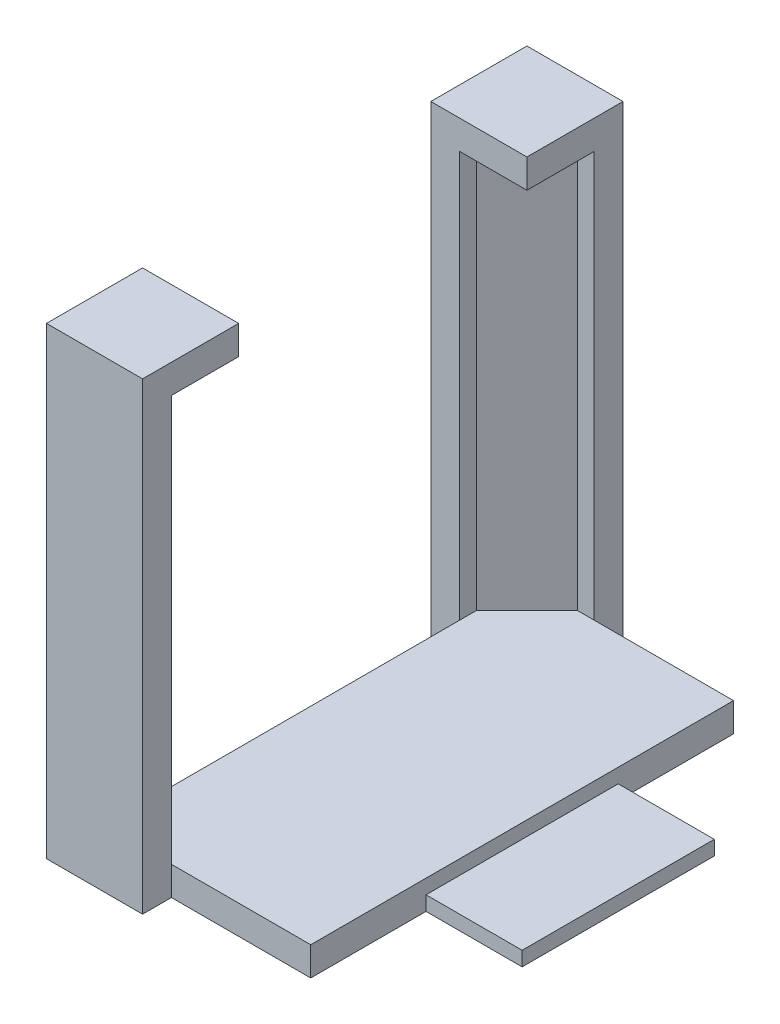
from build123d import *

# Parameters (mm, degrees)
SKETCH1_W           = 21.5
SKETCH1_H           = 44
BOSS_EXTRUDE1_DEPTH = 3
SKETCH1_3_W         = 10
SKETCH1_3_H         = 20
BOSS_EXTRUDE2_DEPTH = 1.5
BOSS_EXTRUDE3_DEPTH = 45.25
SKETCH2_W           = 10
SKETCH2_H           = 10
BOSS_EXTRUDE4_DEPTH = 3
CHAMFER1_SIZE       = 5.25


with BuildPart() as part:
    # Sketch1 → Boss-Extrude1 (new body)
    with BuildSketch(Plane(origin=(0, 0, 0), x_dir=(1, 0, 0), z_dir=(0, 1, 0))):
        with Locations((-10.75, 22)):
            Rectangle(SKETCH1_W, SKETCH1_H)
    extrude(amount=BOSS_EXTRUDE1_DEPTH)

    # Sketch1_3 → Boss-Extrude2 (add)
    with BuildSketch(Plane(origin=(0, 0, 0), x_dir=(1, 0, 0), z_dir=(0, 1, 0))):
        with Locations((5, 22)):
            Rectangle(SKETCH1_3_W, SKETCH1_3_H)
    extrude(amount=BOSS_EXTRUDE2_DEPTH)

    # Sketch1_4 → Boss-Extrude3 (add)
    with BuildSketch(Plane(origin=(0, 0, 0), x_dir=(1, 0, 0), z_dir=(0, 1, 0))):
        Polygon((-14.5, -3), (-14.5, 0), (-21.5, 0), (-21.5, 7), (-24.5, 7), (-24.5, -3), align=None)
        Polygon((-24.5, 37), (-21.5, 37), (-21.5, 44), (-14.5, 44), (-14.5, 47), (-24.5, 47), align=None)
    extrude(amount=BOSS_EXTRUDE3_DEPTH)

    # Sketch2 → Boss-Extrude4 (add)
    with BuildSketch(Plane(origin=(0, 45.25, 0), x_dir=(1, 0, 0), z_dir=(0, 1, 0))):
        with Locations((-19.5, 2)):
            Rectangle(SKETCH2_W, SKETCH2_H)
        with Locations((-19.5, 42)):
            Rectangle(SKETCH2_W, SKETCH2_H)
    extrude(amount=BOSS_EXTRUDE4_DEPTH)

    # Chamfer1
    chamfer1_edges = [part.edges().sort_by_distance(p)[0] for p in [
        (-21.5, 24.125, -44),
        (-21.5, 24.125, 0),
    ]]
    chamfer(chamfer1_edges, length=CHAMFER1_SIZE)


solid = part.part
